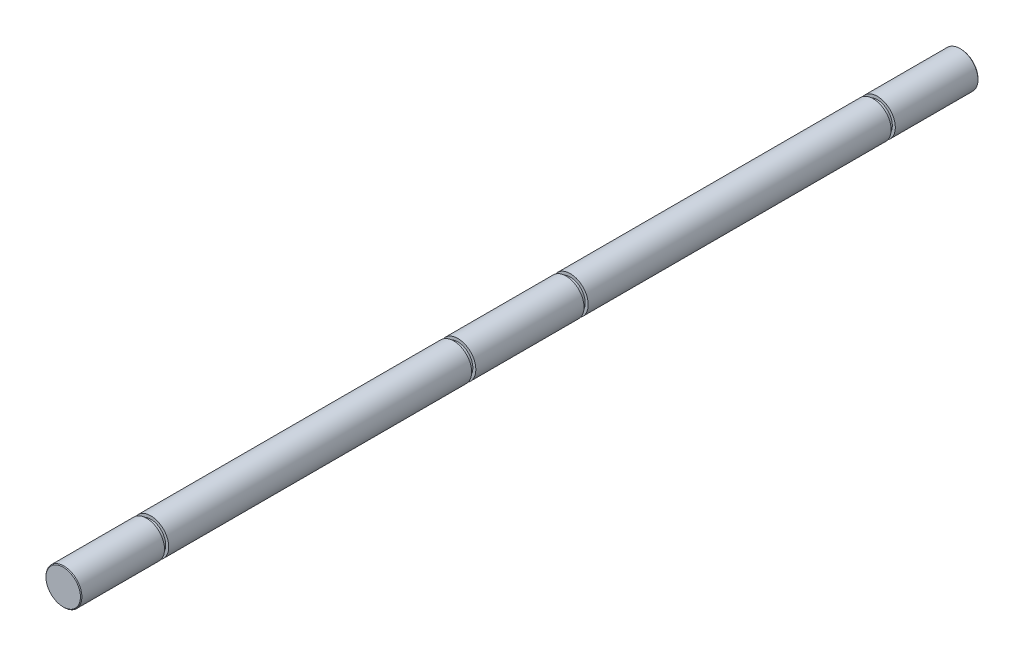
from build123d import *

# Parameters (mm, degrees)
SKETCH2_R                = 3
BOSS_EXTRUDE1_DEPTH      = 75
BOSS_EXTRUDE1_DEPTH_BACK = 75
CHAMFER1_SIZE            = 0.12
CUT_EXTRUDE1_START       = -13.936057366
SKETCH3_R                = 3
SKETCH3_R_2              = 2.5
CUT_EXTRUDE1_DEPTH       = 0.7
CUT_EXTRUDE2_START       = -65.26
SKETCH3_2_R              = 3
SKETCH3_2_R_2            = 2.5
CUT_EXTRUDE2_DEPTH       = 0.7


with BuildPart() as part:
    # Sketch2 → Boss-Extrude1 (new body, two sides)
    with BuildSketch(Plane.XY) as boss_extrude1_sk:
        Circle(SKETCH2_R)
    extrude(amount=BOSS_EXTRUDE1_DEPTH)
    extrude(boss_extrude1_sk.sketch, amount=-BOSS_EXTRUDE1_DEPTH_BACK)

    # Chamfer1
    chamfer1_edges = [part.edges().sort_by_distance(p)[0] for p in [
        (-3, 0, -75),
        (-3, 0, 75),
    ]]
    chamfer(chamfer1_edges, length=CHAMFER1_SIZE)

    # Sketch3 → Cut-Extrude1 (cut)
    with BuildSketch(Plane.XY.offset(75).offset(CUT_EXTRUDE1_START)):
        Circle(SKETCH3_R)
        Circle(SKETCH3_R_2, mode=Mode.SUBTRACT)
    cut_extrude1 = extrude(amount=-CUT_EXTRUDE1_DEPTH, mode=Mode.SUBTRACT)

    # Mirror1: Cut-Extrude1 across plane
    add(cut_extrude1.mirror(Plane.XY), mode=Mode.SUBTRACT)

    # Sketch3_2 → Cut-Extrude2 (cut)
    with BuildSketch(Plane.XY.offset(75).offset(CUT_EXTRUDE2_START)):
        Circle(SKETCH3_2_R)
        Circle(SKETCH3_2_R_2, mode=Mode.SUBTRACT)
    cut_extrude2 = extrude(amount=-CUT_EXTRUDE2_DEPTH, mode=Mode.SUBTRACT)

    # Mirror2: Cut-Extrude2 across plane
    add(cut_extrude2.mirror(Plane.XY), mode=Mode.SUBTRACT)


solid = part.part
